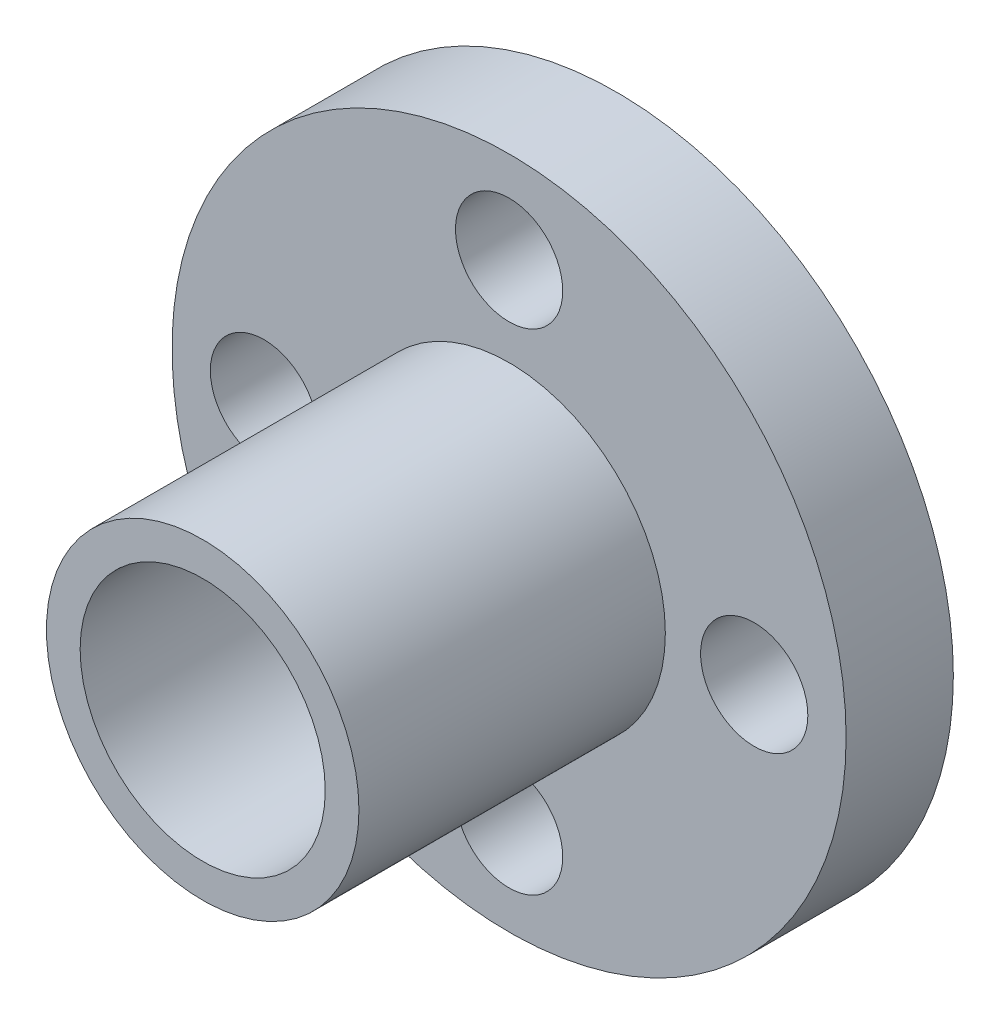
from build123d import *

# Parameters (mm, degrees)
SKETCH1_R                = 11
BOSS_EXTRUDE1_DEPTH      = 3.5
SKETCH2_R                = 4
CUT_EXTRUDE3_DEPTH       = 4.5
SKETCH7_R                = 5.1
SKETCH7_R_2              = 4
BOSS_EXTRUDE3_DEPTH      = 10
BOSS_EXTRUDE3_DEPTH_BACK = 5
SKETCH10_R               = 1.75
CUT_EXTRUDE4_DEPTH       = 6


with BuildPart() as part:
    # Sketch1 → Boss-Extrude1 (new body)
    with BuildSketch(Plane.XY):
        Circle(SKETCH1_R)
    extrude(amount=BOSS_EXTRUDE1_DEPTH)

    # Sketch2 → Cut-Extrude3 (cut, through all)
    with BuildSketch(Plane.XY.offset(3.5)):
        Circle(SKETCH2_R)
    extrude(amount=-CUT_EXTRUDE3_DEPTH, mode=Mode.SUBTRACT)

    # Sketch7 → Boss-Extrude3 (add, two sides)
    with BuildSketch(Plane.XY.offset(3.5)) as boss_extrude3_sk:
        Circle(SKETCH7_R)
        Circle(SKETCH7_R_2, mode=Mode.SUBTRACT)
    extrude(amount=BOSS_EXTRUDE3_DEPTH)
    extrude(boss_extrude3_sk.sketch, amount=-BOSS_EXTRUDE3_DEPTH_BACK)

    # Sketch10 → Cut-Extrude4 (cut, through all)
    with BuildSketch(Plane.XY.offset(3.5)):
        with Locations((8, 0)):
            Circle(SKETCH10_R)
        with Locations((0, -8)):
            Circle(SKETCH10_R)
        with Locations((0, 8)):
            Circle(SKETCH10_R)
        with Locations((-8, 0)):
            Circle(SKETCH10_R)
    extrude(amount=-CUT_EXTRUDE4_DEPTH, mode=Mode.SUBTRACT)


solid = part.part
